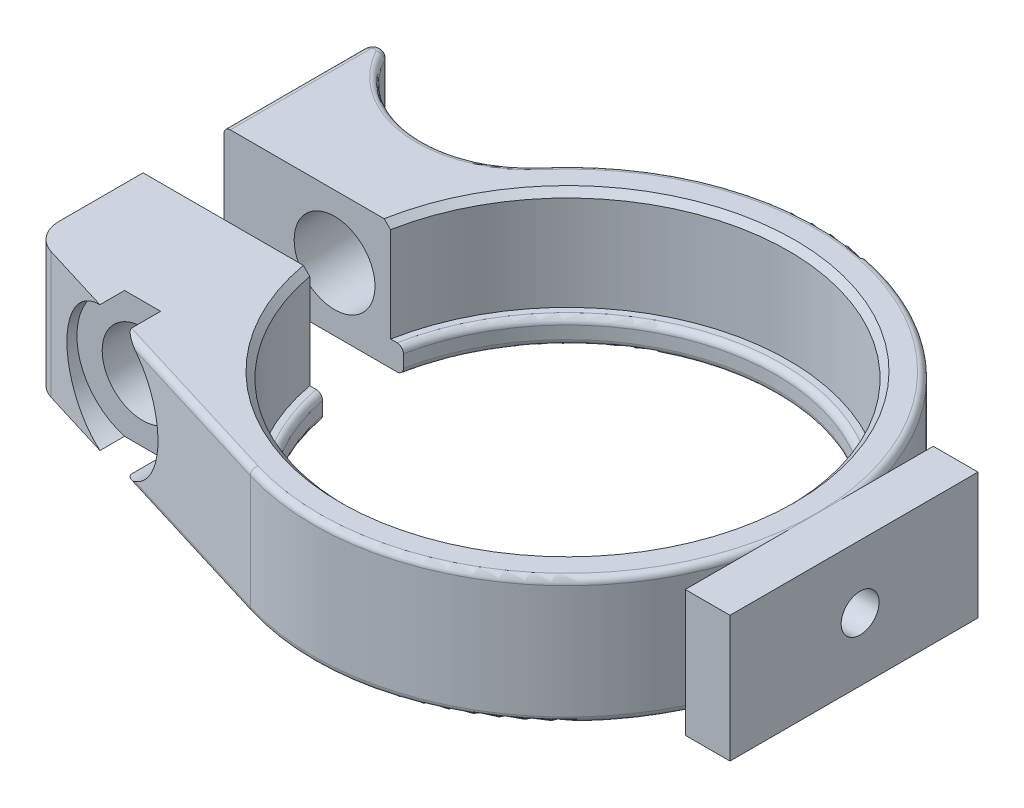
from build123d import *

# Parameters (mm, degrees)
EXTRUDE_1_DEPTH     = 5
SKETCH_2_R          = 17.5
CUT_EXTRUDE_1_DEPTH = 8
CHAMFER_1_SIZE      = 0.5
SKETCH4_W           = 3.538901111
SKETCH4_H           = 19.635193261
BOSS_EXTRUDE1_DEPTH = 10
FILLET_1_R          = 0.5
SKETCH5_R           = 1.5
CUT_EXTRUDE1_DEPTH  = 10


with BuildPart() as part:
    # Эскиз1 → Бобышка-Вытянуть1 (new body, symmetric)
    with BuildSketch(Plane(origin=(0, 0, 0), x_dir=(1, 0, 0), z_dir=(0, 1, 0))):
        with BuildLine():
            ThreePointArc((-28.633085951, -12.241943465), (-29.910312771, -11.337992253), (-30.4, -9.851842005))
            Line((-30.4, -9.851842005), (-30.4, -3.2))
            Line((-30.4, -3.2), (-16.186722954, -3.2))
            ThreePointArc((-16.186722954, -3.2), (16.5, 0), (-16.186722954, 3.2))
            Line((-16.186722954, 3.2), (-30.4, 3.2))
            Line((-30.4, 3.2), (-30.4, 14.265014145))
            ThreePointArc((-30.4, 14.265014145), (-29.874202857, 14.942991552), (-29.086704673, 14.602458721))
            ThreePointArc((-29.086704673, 14.602458721), (-22.528920312, 10.246656558), (-15.208213193, 13.142307692))
            ThreePointArc((-15.208213193, 13.142307692), (19.31573743, 5.559881971), (-5.894011049, -19.216415736))
            Line((-5.894011049, -19.216415736), (-28.633085951, -12.241943465))
        make_face()
    extrude(amount=EXTRUDE_1_DEPTH, both=True)

    # Эскиз2 → Вырез-Вытянуть1 (cut)
    with BuildSketch(Plane(origin=(0, 5, 0), x_dir=(1, 0, 0), z_dir=(0, 1, 0))):
        Circle(SKETCH_2_R)
    extrude(amount=-CUT_EXTRUDE_1_DEPTH, mode=Mode.SUBTRACT)

    # Эскиз4 → Вырез-Повернуть1 (revolve, cut)
    with BuildSketch(Plane(origin=(0, 0, 0), x_dir=(1, 0, 0), z_dir=(0, 1, 0))):
        Polygon((-24.83954713, 16.784760474), (-24.83954713, -12), (-26.83954713, -12), (-26.83954713, -19.633670517), (-21.63954713, -19.633670517), (-21.63954713, 16.784760474), align=None)
    revolve(axis=Axis((-21.63954713, 0, -18.7), (0, 0, 1)), mode=Mode.SUBTRACT)

    # Фаска1
    chamfer_1_edges = [part.edges().sort_by_distance(p)[0] for p in [
        (17.5, 5, 0),
    ]]
    chamfer(chamfer_1_edges, length=CHAMFER_1_SIZE)

    # Скругление1
    fillet_1_edges = [part.edges().sort_by_distance(p)[0] for p in [
        (-13.052636247, -5, 17.020740092),
        (-22.528920312, -5, -10.246656558),
        (-13.052636247, 5, 17.020740092),
        (-22.528920312, 5, -10.246656558),
        (16.5, -3, 0),
        (16.5, -5, 0),
        (19.31573743, -5, -5.559881971),
        (19.31573743, 5, -5.559881971),
        (-30.4, -5, -8.732507073),
        (-29.874202857, -5, -14.942991552),
        (-30.4, 5, -8.732507073),
        (-29.874202857, 5, -14.942991552),
    ]]
    fillet(fillet_1_edges, radius=FILLET_1_R)


with BuildPart() as body_2:
    # Sketch4 → Boss-Extrude1 (new body)
    with BuildSketch(Plane.XZ.offset(5)):
        with Locations((21.398212396, 0.485171926)):
            Rectangle(SKETCH4_W, SKETCH4_H)
    extrude(amount=-BOSS_EXTRUDE1_DEPTH)


with BuildPart() as cut_extrude1_tool:
    # Sketch5 → Cut-Extrude1 (new body)
    with BuildSketch(Plane(origin=(23.167662951, 0, 0), x_dir=(0, 0, -1), z_dir=(1, 0, 0))):
        Circle(SKETCH5_R)
    extrude(amount=-CUT_EXTRUDE1_DEPTH)


with BuildPart() as part_1:
    add(part.part)

    # Cut-Extrude1: cut by cut_extrude1_tool
    add(cut_extrude1_tool.part, mode=Mode.SUBTRACT)


with BuildPart() as body_2_1:
    add(body_2.part)

    # Cut-Extrude1: cut by cut_extrude1_tool
    add(cut_extrude1_tool.part, mode=Mode.SUBTRACT)


solid = Compound([part_1.part, body_2_1.part])
